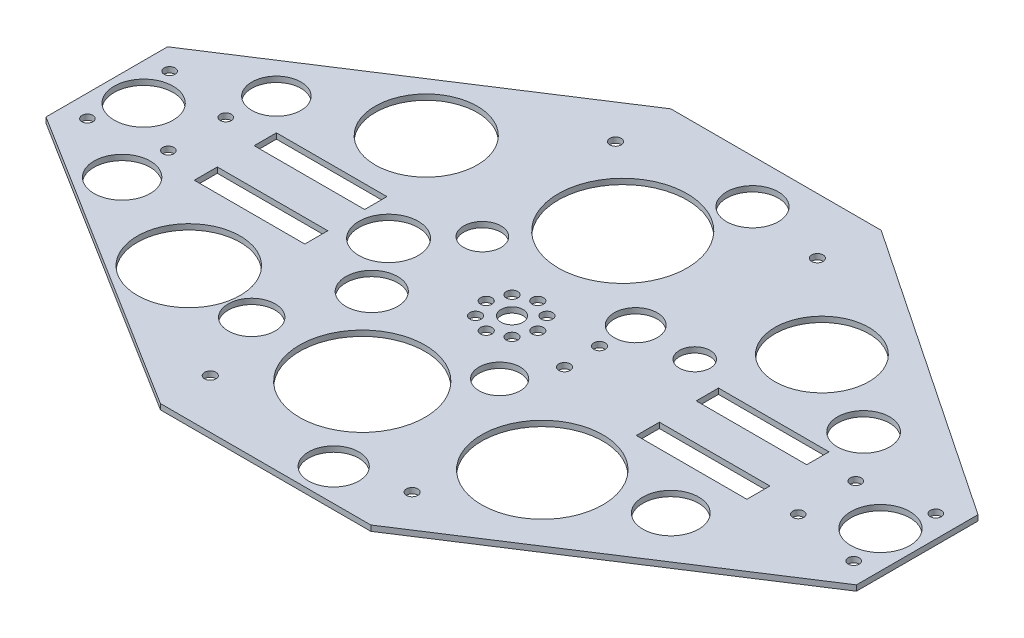
from build123d import *

# Parameters (mm, degrees)
SKETCH_1_R      = 1.5
SKETCH_1_R_2    = 1.55
SKETCH_1_R_3    = 8
SKETCH_1_R_4    = 1.555
SKETCH_1_R_5    = 3
SKETCH_1_R_6    = 17.486246266
SKETCH_1_R_7    = 17.020495335
SKETCH_1_R_8    = 16.467245603
SKETCH_1_R_9    = 13.84365186
SKETCH_1_R_10   = 12.763304461
SKETCH_1_R_11   = 13.972809186
SKETCH_1_R_12   = 7.02721673
SKETCH_1_R_13   = 8.054225091
SKETCH_1_R_14   = 7.029505311
SKETCH_1_R_15   = 5.06480667
SKETCH_1_R_16   = 5.84755638
SKETCH_1_R_17   = 4.172193425
SKETCH_1_R_18   = 7.080536247
SKETCH_1_R_19   = 7.569466987
SKETCH_1_R_20   = 6.673296635
SKETCH_1_R_21   = 7.63323109
SKETCH_1_R_22   = 6.378997066
SKETCH_1_R_23   = 6.842517181
SKETCH_1_R_24   = 5.589183479
SKETCH_1_W      = 30
SKETCH_1_H      = 6.05
SKETCH_1_H_2    = 6.25
EXTRUDE_1_DEPTH = 1.5


with BuildPart() as part:
    # 草图1 → 凸台-拉伸1 (new body)
    with BuildSketch(Plane(origin=(0, 0, 0), x_dir=(1, 0, 0), z_dir=(0, 1, 0))):
        Polygon((0, -33), (82.892637189, -84.836900302), (139.996166095, -84.836900302), (219.992332189, -33), (219.992332189, 0), (139.996166095, 53.713791291), (82.892637189, 53.713791291), (0, 0), align=None)
        with Locations((6, -27.75)):
            Circle(SKETCH_1_R, mode=Mode.SUBTRACT)
        with Locations((6, -5.45)):
            Circle(SKETCH_1_R, mode=Mode.SUBTRACT)
        with Locations((24.5, -8.7)):
            Circle(SKETCH_1_R, mode=Mode.SUBTRACT)
        with Locations((24.5, -24.3)):
            Circle(SKETCH_1_R, mode=Mode.SUBTRACT)
        with Locations((195.5, -8.7)):
            Circle(SKETCH_1_R, mode=Mode.SUBTRACT)
        with Locations((195.5, -24.3)):
            Circle(SKETCH_1_R, mode=Mode.SUBTRACT)
        with Locations((214, -27.75)):
            Circle(SKETCH_1_R, mode=Mode.SUBTRACT)
        with Locations((214, -5.45)):
            Circle(SKETCH_1_R, mode=Mode.SUBTRACT)
        with Locations((105.046418626, -21.449747468)):
            Circle(SKETCH_1_R_2, mode=Mode.SUBTRACT)
        with Locations((114.945913563, -21.449747468)):
            Circle(SKETCH_1_R_2, mode=Mode.SUBTRACT)
        with Locations((10, -16.5)):
            Circle(SKETCH_1_R_3, mode=Mode.SUBTRACT)
        with Locations((210, -16.5)):
            Circle(SKETCH_1_R_3, mode=Mode.SUBTRACT)
        with Locations((114.742384657, -11.753781438)):
            Circle(SKETCH_1_R_2, mode=Mode.SUBTRACT)
        with Locations((83.096166095, 38.5)):
            Circle(SKETCH_1_R_2, mode=Mode.SUBTRACT)
        with Locations((105.046418626, -11.550252532)):
            Circle(SKETCH_1_R_2, mode=Mode.SUBTRACT)
        with Locations((102.996166095, -16.5)):
            Circle(SKETCH_1_R_2, mode=Mode.SUBTRACT)
        with Locations((109.996166095, -23.5)):
            Circle(SKETCH_1_R_4, mode=Mode.SUBTRACT)
        with Locations((116.996166095, -16.5)):
            Circle(SKETCH_1_R_2, mode=Mode.SUBTRACT)
        with Locations((109.996166095, -9.5)):
            Circle(SKETCH_1_R_2, mode=Mode.SUBTRACT)
        with Locations((109.996166095, -16.5)):
            Circle(SKETCH_1_R_5, mode=Mode.SUBTRACT)
        with Locations((129.195913563, -21.449747468)):
            Circle(SKETCH_1_R_2, mode=Mode.SUBTRACT)
        with Locations((128.992384657, -11.753781438)):
            Circle(SKETCH_1_R_2, mode=Mode.SUBTRACT)
        with Locations((137.896166095, 38.5)):
            Circle(SKETCH_1_R_2, mode=Mode.SUBTRACT)
        with Locations((137.896166095, -71.5)):
            Circle(SKETCH_1_R_2, mode=Mode.SUBTRACT)
        with Locations((83.096166095, -71.5)):
            Circle(SKETCH_1_R_2, mode=Mode.SUBTRACT)
        with Locations((105.046418626, 18.503675588)):
            Circle(SKETCH_1_R_6, mode=Mode.SUBTRACT)
        with Locations((105.046418626, -52.199044439)):
            Circle(SKETCH_1_R_7, mode=Mode.SUBTRACT)
        with Locations((150.29958532, -48.585783177)):
            Circle(SKETCH_1_R_8, mode=Mode.SUBTRACT)
        with Locations((55.978889615, 14.234912262)):
            Circle(SKETCH_1_R_9, mode=Mode.SUBTRACT)
        with Locations((161.159046839, 16.460208899)):
            Circle(SKETCH_1_R_10, mode=Mode.SUBTRACT)
        with Locations((54.344707062, -48.585783177)):
            Circle(SKETCH_1_R_11, mode=Mode.SUBTRACT)
        with Locations((116.996166095, 41.77756602)):
            Circle(SKETCH_1_R_12, mode=Mode.SUBTRACT)
        with Locations((75.041941004, -15.050367065)):
            Circle(SKETCH_1_R_13, mode=Mode.SUBTRACT)
        with Locations((85.237439413, -29.806396783)):
            Circle(SKETCH_1_R_14, mode=Mode.SUBTRACT)
        with Locations((87.36558551, -1.911662428)):
            Circle(SKETCH_1_R_15, mode=Mode.SUBTRACT)
        with Locations((128.992384657, -1.911662428)):
            Circle(SKETCH_1_R_16, mode=Mode.SUBTRACT)
        with Locations((145.020577925, -1.911662428)):
            Circle(SKETCH_1_R_17, mode=Mode.SUBTRACT)
        with Locations((185, 3.935893952)):
            Circle(SKETCH_1_R_18, mode=Mode.SUBTRACT)
        with Locations((177.919463753, -41.321628131)):
            Circle(SKETCH_1_R_19, mode=Mode.SUBTRACT)
        with Locations((26.38546357, 3.153144243)):
            Circle(SKETCH_1_R_20, mode=Mode.SUBTRACT)
        with Locations((24.5, -36.835902094)):
            Circle(SKETCH_1_R_21, mode=Mode.SUBTRACT)
        with Locations((75.041941004, -52.199044439)):
            Circle(SKETCH_1_R_22, mode=Mode.SUBTRACT)
        with Locations((121.206538505, -76.107131723)):
            Circle(SKETCH_1_R_23, mode=Mode.SUBTRACT)
        with Locations((123.144828277, -33)):
            Circle(SKETCH_1_R_24, mode=Mode.SUBTRACT)
        with Locations((170, -8.475)):
            Rectangle(SKETCH_1_W, SKETCH_1_H, mode=Mode.SUBTRACT)
        with Locations((170, -24.625)):
            Rectangle(SKETCH_1_W, SKETCH_1_H_2, mode=Mode.SUBTRACT)
        with Locations((50, -24.625)):
            Rectangle(SKETCH_1_W, SKETCH_1_H_2, mode=Mode.SUBTRACT)
        with Locations((50, -8.475)):
            Rectangle(SKETCH_1_W, SKETCH_1_H, mode=Mode.SUBTRACT)
    extrude(amount=EXTRUDE_1_DEPTH)


solid = part.part
